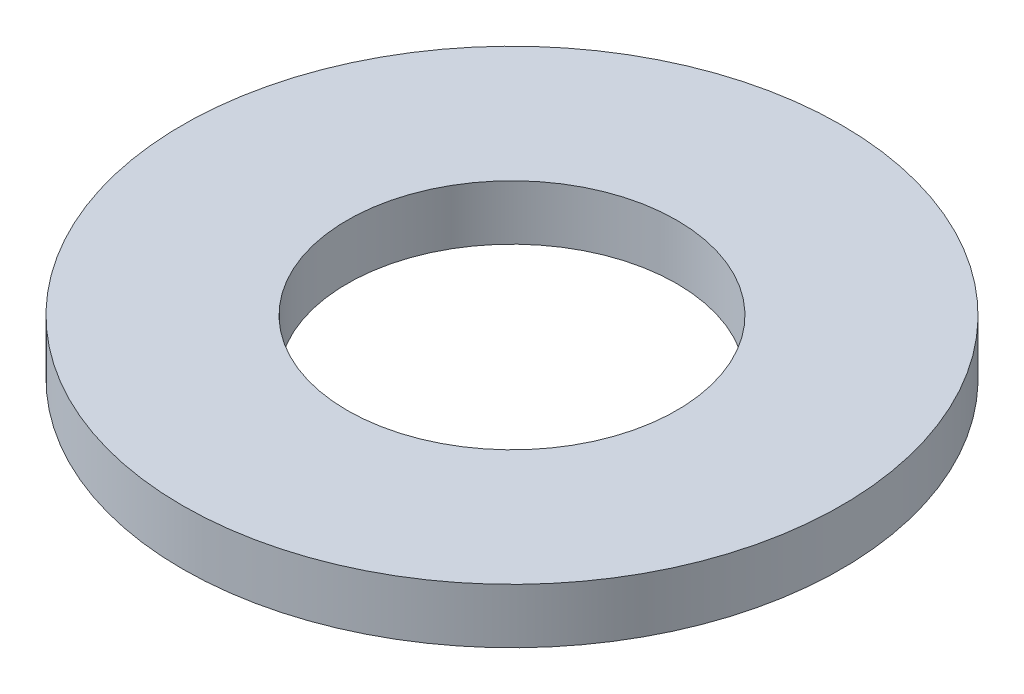
from build123d import *

# Parameters (mm, degrees)
SKETCH1_R           = 3
SKETCH1_R_2         = 1.5
BOSS_EXTRUDE1_DEPTH = 0.5


with BuildPart() as part:
    # Sketch1 → Boss-Extrude1 (new body)
    with BuildSketch(Plane(origin=(0, 0, 0), x_dir=(1, 0, 0), z_dir=(0, 1, 0))):
        Circle(SKETCH1_R)
        Circle(SKETCH1_R_2, mode=Mode.SUBTRACT)
    extrude(amount=BOSS_EXTRUDE1_DEPTH)


solid = part.part
